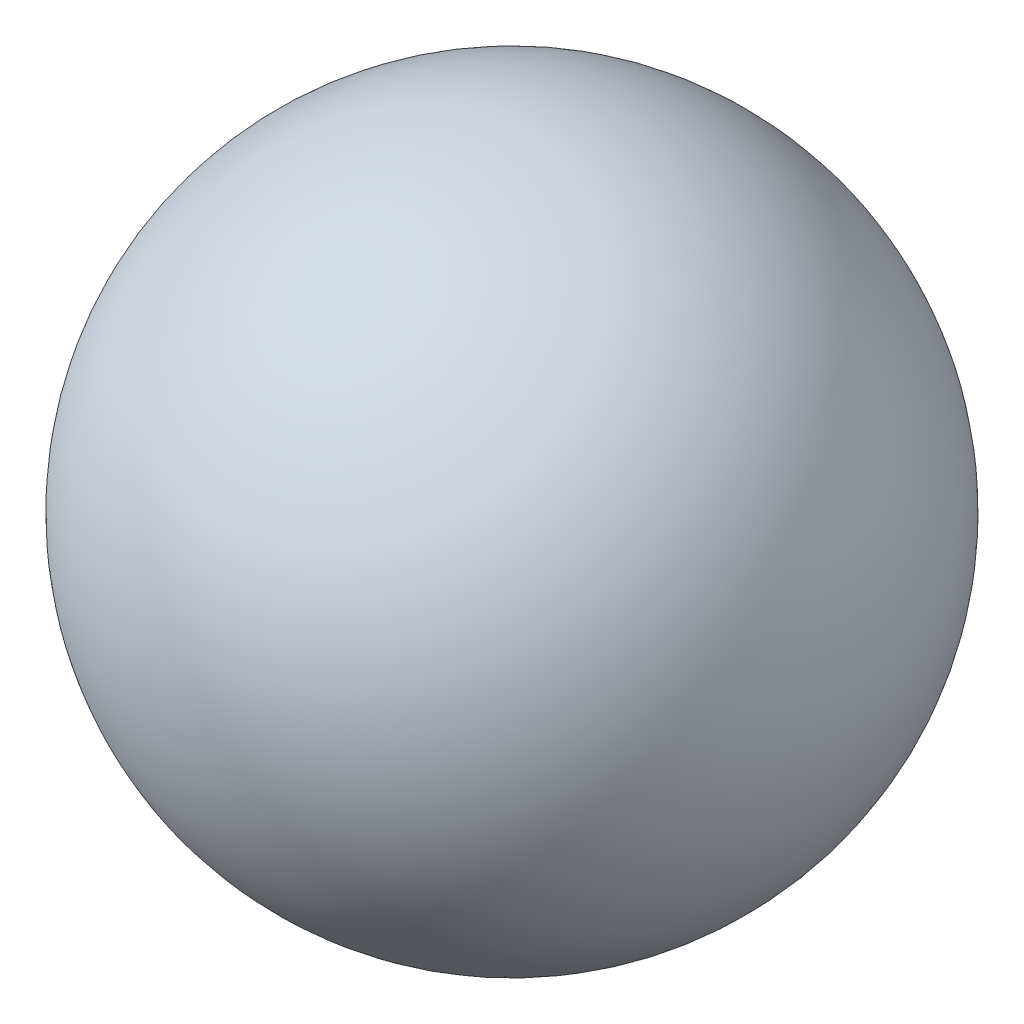
from build123d import *


with BuildPart() as part:
    # Croquis1 → Revolución5 (revolve)
    with BuildSketch(Plane(origin=(0, 0, 0), x_dir=(1, 0, 0), z_dir=(0, 1, 0))):
        with BuildLine():
            Line((0, 4.75), (0, -4.75))
            ThreePointArc((0, -4.75), (4.75, 0), (0, 4.75))
        make_face()
    revolve(axis=Axis((0, 0, -4.75), (0, 0, 1)))


solid = part.part
